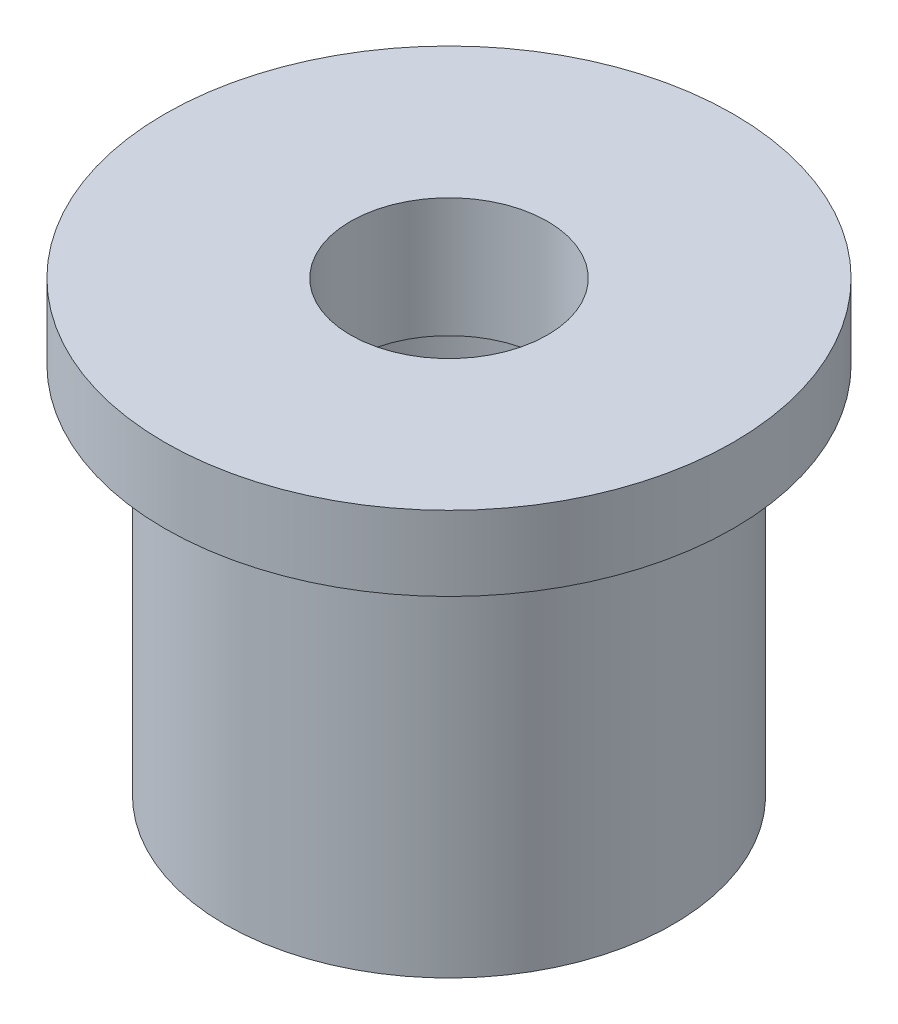
from build123d import *


with BuildPart() as part:
    # Sketch1 → Revolve1 (revolve)
    with BuildSketch(Plane.XY, mode=Mode.PRIVATE) as revolve1_sk:
        Polygon((7.5, 0), (7.5, 12.5), (9.525, 12.5), (9.525, 15), (3.3, 15), (3.3, 11), (5, 11), (5, 9), (4.3235, 9), (5, 8.5), (4.3235, 8), (5, 7.5), (4.3235, 7), (5, 6.5), (4.3235, 6), (5, 5.5), (4.3235, 5), (5, 4.5), (4.3235, 4), (5, 3.5), (4.3235, 3), (5, 2.5), (4.3235, 2), (5, 1.5), (4.3235, 1), (5, 0.5), (4.3235, 0), align=None)
    revolve(revolve1_sk.sketch.rotate(Axis((0, 0, 0), (0, 1, 0)), 90), axis=Axis((0, 0, 0), (0, 1, 0)))  # turned: the seam where the file's is


solid = part.part
